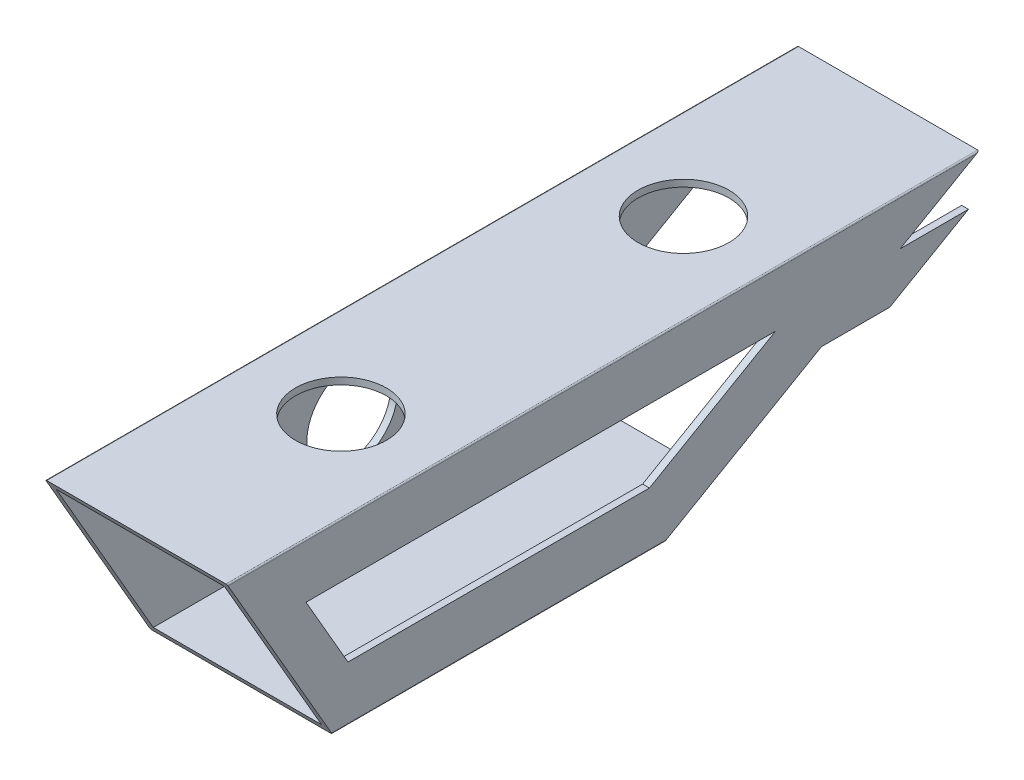
from build123d import *

# Parameters (mm, degrees)
SKETCH1_W           = 37
SKETCH1_H           = 37
BOSS_EXTRUDE1_DEPTH = 165.35
CUT_EXTRUDE1_DEPTH  = 50
BOSS_EXTRUDE2_START = -10
BOSS_EXTRUDE2_DEPTH = 20
BOSS_EXTRUDE3_START = -40
BOSS_EXTRUDE3_DEPTH = 1.5
CUT_EXTRUDE2_DEPTH  = 10
SKETCH6_R           = 10
CUT_EXTRUDE3_DEPTH  = 10
SKETCH7_R           = 10
CUT_EXTRUDE4_DEPTH  = 10


with BuildPart() as part:
    # Sketch1 → Boss-Extrude1 (new body)
    with BuildSketch(Plane.XY):
        with BuildLine():
            Line((0.305025041, 0), (39.694974959, 0))
            ThreePointArc((39.694974959, 0), (39.910660234, 0.089339766), (40, 0.305025041))
            Line((40, 0.305025041), (40, 39.694974959))
            ThreePointArc((40, 39.694974959), (39.910660234, 39.910660234), (39.694974959, 40))
            Line((39.694974959, 40), (0.305025041, 40))
            ThreePointArc((0.305025041, 40), (0.089339766, 39.910660234), (0, 39.694974959))
            Line((0, 39.694974959), (0, 0.305025041))
            ThreePointArc((0, 0.305025041), (0.089339766, 0.089339766), (0.305025041, 0))
        make_face()
        with Locations((20, 20)):
            Rectangle(SKETCH1_W, SKETCH1_H, mode=Mode.SUBTRACT)
    extrude(amount=BOSS_EXTRUDE1_DEPTH)

    # Sketch2 → Cut-Extrude1 (cut)
    with BuildSketch(Plane(origin=(40, 0, 0), x_dir=(0, 0, -1), z_dir=(1, 0, 0))):
        Polygon((0, 40), (-69.282032303, 0), (0, 0), align=None)
        Polygon((-165.35, 40), (-142.255989232, 0), (-165.35, 0), align=None)
    extrude(amount=-CUT_EXTRUDE1_DEPTH, mode=Mode.SUBTRACT)

    # Sketch3 → Boss-Extrude2 (add)
    with BuildSketch(Plane.ZY.offset(BOSS_EXTRUDE2_START)):
        Polygon((69.282032303, 0), (52.282032303, 0), (52.282032303, 1.5), (66.683956091, 1.5), align=None)
    extrude(amount=-BOSS_EXTRUDE2_DEPTH)

    # Sketch4 → Boss-Extrude3 (add)
    with BuildSketch(Plane.ZY.offset(BOSS_EXTRUDE3_START)):
        Polygon((2.320508076, 30), (19.641016151, 20), (34.641016151, 20), (17.320508076, 30), align=None)
    extrude(amount=BOSS_EXTRUDE3_DEPTH)

    # Sketch5 → Cut-Extrude2 (cut)
    with BuildSketch(Plane(origin=(40, 0, 0), x_dir=(0, 0, -1), z_dir=(1, 0, 0))):
        Polygon((-44.784609691, 28), (-72.497422612, 12), (-138.791887617, 12), (-148.029491924, 28), align=None)
    extrude(amount=-CUT_EXTRUDE2_DEPTH, mode=Mode.SUBTRACT)

    # Sketch6 → Cut-Extrude3 (cut)
    with BuildSketch(Plane(origin=(0, 40, 0), x_dir=(1, 0, 0), z_dir=(0, 1, 0))):
        with Locations(Location((20, -120.35, 0), (0, 0, 180))):
            Circle(SKETCH6_R)
        with Locations(Location((20, -45, 0), (0, 0, 90))):
            Circle(SKETCH6_R)
    extrude(amount=-CUT_EXTRUDE3_DEPTH, mode=Mode.SUBTRACT)

    # Sketch7 → Cut-Extrude4 (cut)
    with BuildSketch(Plane(origin=(1.5, 0, 0), x_dir=(0, 0, -1), z_dir=(1, 0, 0))):
        with Locations((-99.35, 20)):
            Circle(SKETCH7_R)
    extrude(amount=-CUT_EXTRUDE4_DEPTH, mode=Mode.SUBTRACT)


solid = part.part
